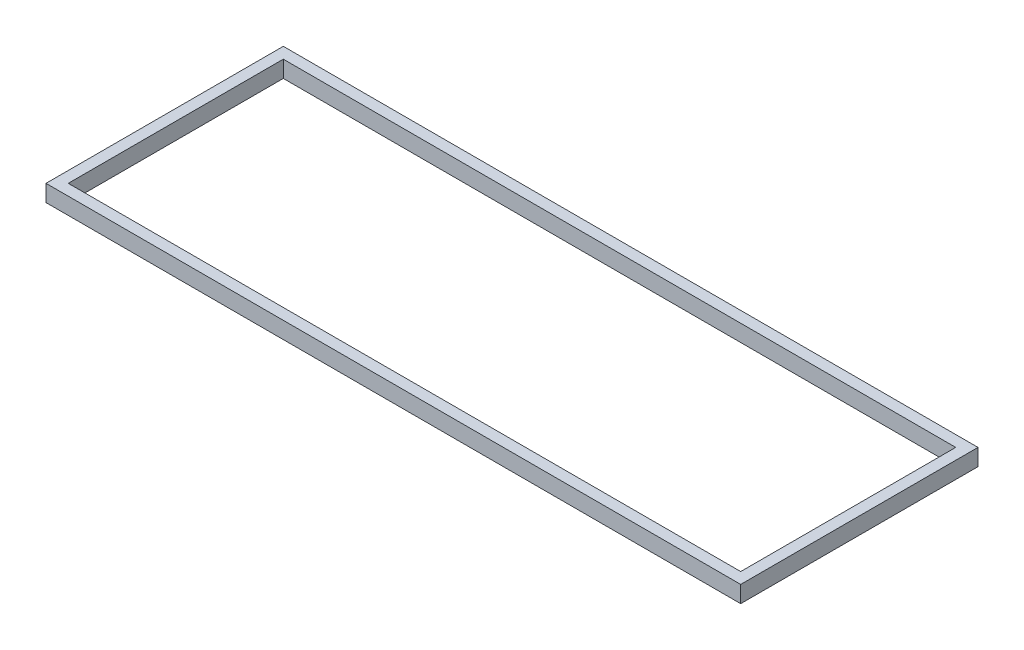
from build123d import *

# Parameters (mm, degrees)
ESQUISSE1_W        = 249.56
ESQUISSE1_H        = 85.25
ESQUISSE1_W_2      = 241.56
ESQUISSE1_H_2      = 77.25
BOSS_EXTRU_1_DEPTH = 6


with BuildPart() as part:
    # Esquisse1 → Boss.-Extru.1 (new body)
    with BuildSketch(Plane(origin=(0, 0, 0), x_dir=(1, 0, 0), z_dir=(0, 1, 0))):
        with Locations((124.78, 42.625)):
            Rectangle(ESQUISSE1_W, ESQUISSE1_H)
        with Locations((124.78, 42.625)):
            Rectangle(ESQUISSE1_W_2, ESQUISSE1_H_2, mode=Mode.SUBTRACT)
    extrude(amount=BOSS_EXTRU_1_DEPTH)


solid = part.part
